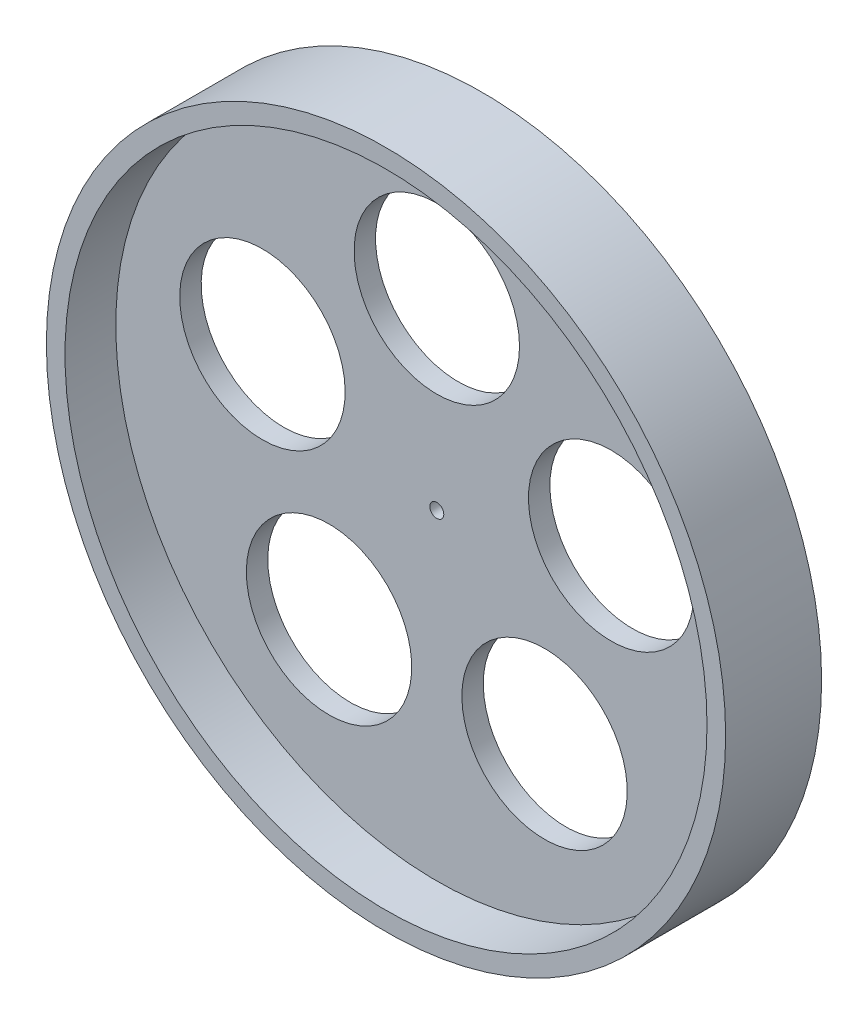
from build123d import *

# Parameters (mm, degrees)
SKETCH1_R                = 68.9
BOSS_EXTRUDE1_DEPTH      = 2.3
SKETCH2_R                = 17.75
CUT_EXTRUDE1_DEPTH       = 98.54783442
CIRPATTERN1_COUNT        = 5
BOSS_EXTRUDE2_DEPTH      = 10.9
BOSS_EXTRUDE2_DEPTH_BACK = 9.7
SKETCH3_R                = 72.9
SKETCH3_R_2              = 68.9
SKETCH4_R                = 11.65
BOSS_EXTRUDE3_DEPTH      = 8
SKETCH6_R                = 1.5
CUT_EXTRUDE2_DEPTH       = 104.863275512


with BuildPart() as part:
    # Sketch1 → Boss-Extrude1 (new, symmetric)
    with BuildSketch(Plane.XY):
        Circle(SKETCH1_R)
    extrude(amount=BOSS_EXTRUDE1_DEPTH, both=True)

    # Sketch2 → Cut-Extrude1 (cut, through all)
    with BuildSketch(Plane.XY.offset(2.3)):
        with Locations((0, 39.35)):
            Circle(SKETCH2_R)
    cut_extrude1 = extrude(amount=-CUT_EXTRUDE1_DEPTH, mode=Mode.SUBTRACT)

    # CirPattern1: Cut-Extrude1 ×5 about axis
    cirpattern1_axis = Axis((0, 0, -88.99), (0, 0, 1))
    for i in range(1, CIRPATTERN1_COUNT):
        add(cut_extrude1.rotate(cirpattern1_axis, i * 360 / CIRPATTERN1_COUNT), mode=Mode.SUBTRACT)

    # Sketch3 → Boss-Extrude2 (add, two sides: drawn at the far end of the back side and taken through both)
    with BuildSketch(Plane.XY.offset(2.3).offset(-BOSS_EXTRUDE2_DEPTH_BACK)):
        Circle(SKETCH3_R)
        Circle(SKETCH3_R_2, mode=Mode.SUBTRACT)
    extrude(amount=BOSS_EXTRUDE2_DEPTH + BOSS_EXTRUDE2_DEPTH_BACK)

    # Sketch4 → Boss-Extrude3 (add)
    with BuildSketch(Plane(origin=(0, 0, -2.3), x_dir=(-1, 0, 0), z_dir=(0, 0, -1))):
        Circle(SKETCH4_R)
    extrude(amount=BOSS_EXTRUDE3_DEPTH)

    # Sketch6 → Cut-Extrude2 (cut, through all)
    with BuildSketch(Plane.XY.offset(2.3)):
        Circle(SKETCH6_R)
    extrude(amount=-CUT_EXTRUDE2_DEPTH, mode=Mode.SUBTRACT)


solid = part.part
